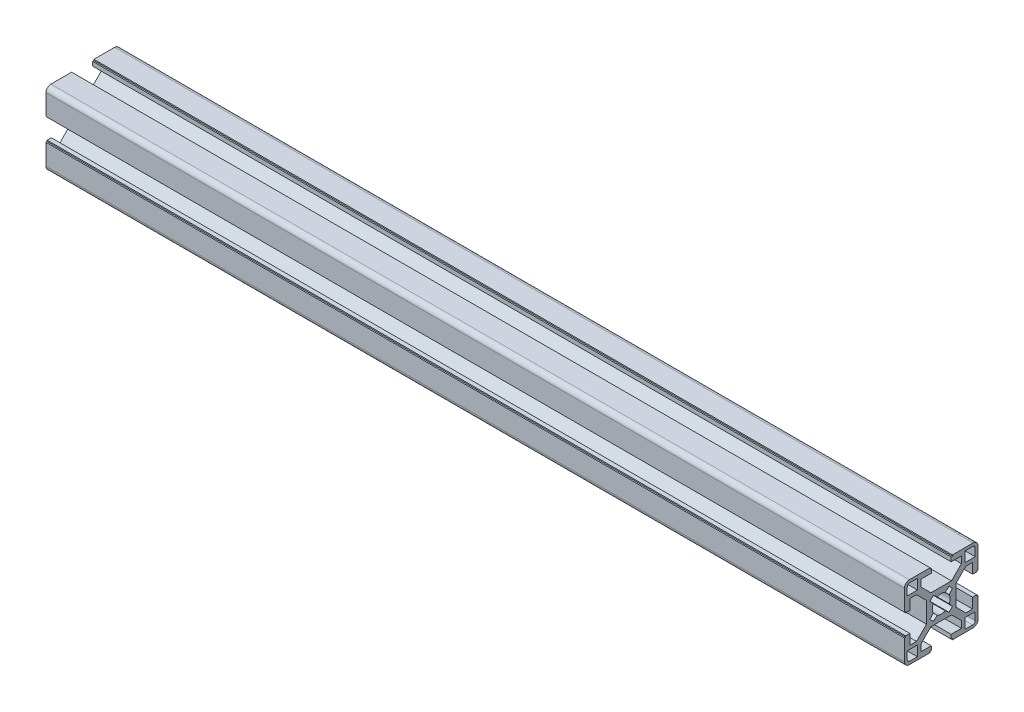
from build123d import *

# Parameters (mm, degrees)
BR_EXTRUDE_DEPTH      = 175
BR_EXTRUDE_DEPTH_BACK = 175


with BuildPart() as part:
    # Sketch2 → BR_Extrude (new body, two sides)
    with BuildSketch(Plane(origin=(0, 0, 0), x_dir=(0, 0, -1), z_dir=(1, 0, 0))) as br_extrude_sk:
        with BuildLine():
            Line((-6, 4.196877708), (-10.053122292, 8.25))
            Line((-10.053122292, 8.25), (-12.8, 8.25))
            Line((-12.8, 8.25), (-12.800036742, 4.05))
            Line((-12.800036742, 4.05), (-14.5, 4.05))
            Line((-14.5, 4.05), (-14.5, 4.55))
            Line((-14.5, 4.55), (-15, 4.55))
            Line((-15, 4.55), (-15, 13))
            ThreePointArc((-15, 13), (-14.414213562, 14.414213562), (-13, 15))
            Line((-13, 15), (-4.55, 15))
            Line((-4.55, 15), (-4.55, 14.5))
            Line((-4.55, 14.5), (-4.05, 14.5))
            Line((-4.05, 14.5), (-4.05, 12.800036742))
            Line((-4.05, 12.800036742), (-8.25, 12.8))
            Line((-8.25, 12.8), (-8.25, 10.053122292))
            Line((-8.25, 10.053122292), (-4.196877708, 6))
            Line((-4.196877708, 6), (4.196877708, 6))
            Line((4.196877708, 6), (8.25, 10.053122292))
            Line((8.25, 10.053122292), (8.25, 12.8))
            Line((8.25, 12.8), (4.05, 12.800036742))
            Line((4.05, 12.800036742), (4.05, 14.5))
            Line((4.05, 14.5), (4.55, 14.5))
            Line((4.55, 14.5), (4.55, 15))
            Line((4.55, 15), (13, 15))
            ThreePointArc((13, 15), (14.414213562, 14.414213562), (15, 13))
            Line((15, 13), (15, 4.55))
            Line((15, 4.55), (14.5, 4.55))
            Line((14.5, 4.55), (14.5, 4.05))
            Line((14.5, 4.05), (12.800036742, 4.05))
            Line((12.800036742, 4.05), (12.8, 8.25))
            Line((12.8, 8.25), (10.053122292, 8.25))
            Line((10.053122292, 8.25), (6, 4.196877708))
            Line((6, 4.196877708), (6, -4.196877708))
            Line((6, -4.196877708), (10.053122292, -8.25))
            Line((10.053122292, -8.25), (12.8, -8.25))
            Line((12.8, -8.25), (12.800036742, -4.05))
            Line((12.800036742, -4.05), (14.5, -4.05))
            Line((14.5, -4.05), (14.5, -4.55))
            Line((14.5, -4.55), (15, -4.55))
            Line((15, -4.55), (15, -13))
            ThreePointArc((15, -13), (14.414213562, -14.414213562), (13, -15))
            Line((13, -15), (4.55, -15))
            Line((4.55, -15), (4.55, -14.5))
            Line((4.55, -14.5), (4.05, -14.5))
            Line((4.05, -14.5), (4.05, -12.800036742))
            Line((4.05, -12.800036742), (8.25, -12.8))
            Line((8.25, -12.8), (8.25, -10.053122292))
            Line((8.25, -10.053122292), (4.196877708, -6))
            Line((4.196877708, -6), (-4.196877708, -6))
            Line((-4.196877708, -6), (-8.25, -10.053122292))
            Line((-8.25, -10.053122292), (-8.25, -12.8))
            Line((-8.25, -12.8), (-4.05, -12.800036742))
            Line((-4.05, -12.800036742), (-4.05, -14.5))
            Line((-4.05, -14.5), (-4.55, -14.5))
            Line((-4.55, -14.5), (-4.55, -15))
            Line((-4.55, -15), (-13, -15))
            ThreePointArc((-13, -15), (-14.414213562, -14.414213562), (-15, -13))
            Line((-15, -13), (-15, -4.55))
            Line((-15, -4.55), (-14.5, -4.55))
            Line((-14.5, -4.55), (-14.5, -4.05))
            Line((-14.5, -4.05), (-12.800036742, -4.05))
            Line((-12.800036742, -4.05), (-12.8, -8.25))
            Line((-12.8, -8.25), (-10.053122292, -8.25))
            Line((-10.053122292, -8.25), (-6, -4.196877708))
            Line((-6, -4.196877708), (-6, 4.196877708))
        make_face()
        with BuildLine():
            Line((-13.85, -9.7), (-13.85, -12.85))
            ThreePointArc((-13.85, -12.85), (-13.557106781, -13.557106781), (-12.85, -13.85))
            Line((-12.85, -13.85), (-9.7, -13.85))
            Line((-9.7, -13.85), (-9.7, -9.7))
            Line((-9.7, -9.7), (-13.85, -9.7))
        make_face(mode=Mode.SUBTRACT)
        with BuildLine():
            Line((9.7, -13.85), (12.85, -13.85))
            ThreePointArc((12.85, -13.85), (13.557106781, -13.557106781), (13.85, -12.85))
            Line((13.85, -12.85), (13.85, -9.7))
            Line((13.85, -9.7), (9.7, -9.7))
            Line((9.7, -9.7), (9.7, -13.85))
        make_face(mode=Mode.SUBTRACT)
        with BuildLine():
            Line((13.85, 9.7), (13.85, 12.85))
            ThreePointArc((13.85, 12.85), (13.557106781, 13.557106781), (12.85, 13.85))
            Line((12.85, 13.85), (9.7, 13.85))
            Line((9.7, 13.85), (9.7, 9.7))
            Line((9.7, 9.7), (13.85, 9.7))
        make_face(mode=Mode.SUBTRACT)
        with BuildLine():
            Line((-9.7, 13.85), (-12.85, 13.85))
            ThreePointArc((-12.85, 13.85), (-13.557106781, 13.557106781), (-13.85, 12.85))
            Line((-13.85, 12.85), (-13.85, 9.7))
            Line((-13.85, 9.7), (-9.7, 9.7))
            Line((-9.7, 9.7), (-9.7, 13.85))
        make_face(mode=Mode.SUBTRACT)
        with BuildLine():
            Line((-3.272394192, -1.616767223), (-4.59052283, -3.187651763))
            Line((-4.59052283, -3.187651763), (-3.187651763, -4.59052283))
            Line((-3.187651763, -4.59052283), (-1.616767223, -3.272394192))
            ThreePointArc((-1.616767223, -3.272394192), (0, -3.65), (1.616767223, -3.272394192))
            Line((1.616767223, -3.272394192), (3.187651763, -4.59052283))
            Line((3.187651763, -4.59052283), (4.59052283, -3.187651763))
            Line((4.59052283, -3.187651763), (3.272394192, -1.616767223))
            ThreePointArc((3.272394192, -1.616767223), (3.65, 0), (3.272394192, 1.616767223))
            Line((3.272394192, 1.616767223), (4.59052283, 3.187651763))
            Line((4.59052283, 3.187651763), (3.187651763, 4.59052283))
            Line((3.187651763, 4.59052283), (1.616767223, 3.272394192))
            ThreePointArc((1.616767223, 3.272394192), (0, 3.65), (-1.616767223, 3.272394192))
            Line((-1.616767223, 3.272394192), (-3.187651763, 4.59052283))
            Line((-3.187651763, 4.59052283), (-4.59052283, 3.187651763))
            Line((-4.59052283, 3.187651763), (-3.272394192, 1.616767223))
            ThreePointArc((-3.272394192, 1.616767223), (-3.65, 0), (-3.272394192, -1.616767223))
        make_face(mode=Mode.SUBTRACT)
    extrude(amount=BR_EXTRUDE_DEPTH)
    extrude(br_extrude_sk.sketch, amount=-BR_EXTRUDE_DEPTH_BACK)


solid = part.part
